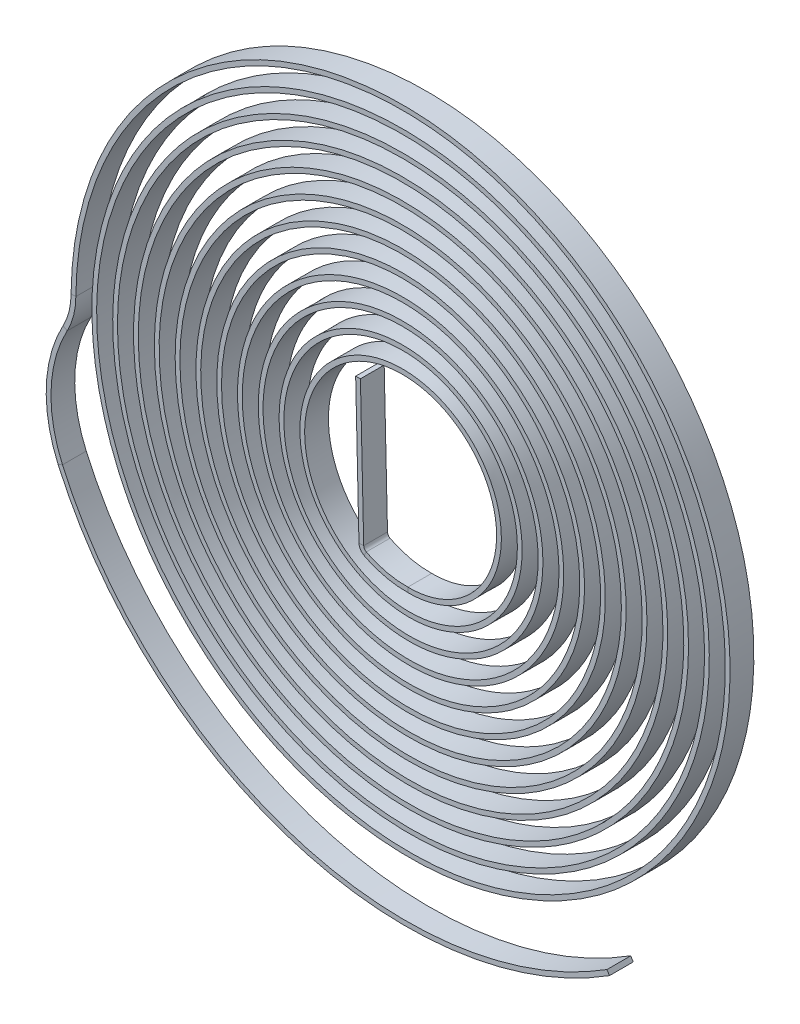
from build123d import *

# Parameters (mm, degrees)
SKETCH5_W = 0.05
SKETCH5_H = 0.25


with BuildPart() as part:
    # Sweep1: sweep along a curve in space
    with BuildLine() as sweep1_path:
        Line((-0.527391727, 0.74651346, 0), (-0.492657587, -0.75616698, 0))
        ThreePointArc((-0.492657587, -0.75616698, 0), (-0.477577264, -0.806706693, 0), (-0.438882443, -0.842545074, 0))
        ThreePointArc((-0.438882443, -0.842545074, 0), (-0.215245274, -0.925294262, 0), (0.021953184, -0.949746312, 0))
        add(Edge.make_bspline(
            [(0.021953184, -0.949746312, 0), (0.20464789, -0.952217859, 0), (0.389822394, -0.900506936, 0), (0.705202842, -0.70109414, 0), (0.834782567, -0.553674341, 0), (0.99342503, -0.207439698, 0), (1.022111196, -0.009215641, 0), (0.964949134, 0.375118929, 0), (0.879109832, 0.56051511, 0), (0.616350676, 0.85714961, 0), (0.439837367, 0.9677838, 0), (0.050338028, 1.075010841, 0), (-0.161964222, 1.07131561, 0), (-0.554221229, 0.946279934, 0), (-0.733432515, 0.825075444, 0), (-0.998794363, 0.500277335, 0), (-1.084387269, 0.297214126, 0), (-1.130364799, -0.127435335, 0), (-1.090570022, -0.348258959, 0), (-0.893905568, -0.736091011, 0), (-0.73730797, -0.902350026, 0), (-0.354208962, -1.123922593, 0), (-0.128356523, -1.17874959, 0), (0.321291507, -1.155007637, 0), (0.544263847, -1.076385751, 0), (0.91437221, -0.806619657, 0), (1.060778159, -0.615888457, 0), (1.226517515, -0.180675337, 0), (1.245459442, 0.063049115, 0), (1.145290213, 0.525749128, 0), (1.026267168, 0.743862673, 0), (0.684408327, 1.082421421, 0), (0.462126557, 1.202182446, 0), (-0.016633508, 1.300983988, 0), (-0.272260576, 1.279750531, 0), (-0.734587541, 1.098561932, 0), (-0.940411583, 0.938846633, 0), (-1.233529618, 0.528506447, 0), (-1.32021229, 0.278571719, 0), (-1.342365518, -0.232943032, 0), (-1.277699606, -0.49359721, 0), (-1.013310654, -0.941030531, 0), (-0.813985384, -1.126947258, 0), (-0.3414131, -1.361153696, 0), (-0.068982405, -1.408931383, 0), (0.462509511, -1.34654693, 0), (0.720593398, -1.236402564, 0), (1.137955304, -0.889268715, 0), (1.296413155, -0.652836161, 0), (1.459150423, -0.126864699, 0), (1.463042085, 0.161746722, 0), (1.310435649, 0.698772172, 0), (1.154122275, 0.946183908, 0), (0.727480682, 1.31812047, 0), (0.457864509, 1.441896813, 0), (-0.11023446, 1.522005159, 0), (-0.407698379, 1.478096248, 0), (-0.934538113, 1.232115061, 0), (-1.1629159, 1.030402496, 0), (-1.47440607, 0.530329578, 0), (-1.556870762, 0.232826923, 0), (-1.545047719, -0.363923108, 0), (-1.450685194, -0.662084369, 0), (-1.110964188, -1.162194846, 0), (-0.866143247, -1.363181376, 0), (-0.301519611, -1.600058144, 0), (0.017294601, -1.635429263, 0), (0.627332879, -1.524647991, 0), (0.917431554, -1.378602102, 0), (1.373944339, -0.947738853, 0), (1.5394631, -0.66363413, 0), (1.68893002, -0.046014742, 0), (1.672513095, 0.286400713, 0), (1.458384414, 0.892873398, 0), (1.260970793, 1.165797003, 0), (0.744610638, 1.562051562, 0), (0.426543335, 1.684586417, 0), (-0.230066154, 1.73571247, 0), (-0.567423277, 1.66411481, 0), (-1.15244761, 1.34517913, 0), (-1.399006244, 1.098335794, 0), (-1.71909999, 0.505161191, 0), (-1.791969046, 0.15986144, 0), (-1.736145006, -0.519595406, 0), (-1.607457315, -0.852510718, 0), (-1.185394525, -1.39769131, 0), (-0.892709725, -1.608907623, 0), (-0.234330781, -1.838246071, 0), (0.130199499, -1.855860818, 0), (0.814620467, -1.687201064, 0), (1.133245324, -1.50113932, 0), (1.620229955, -0.980886984, 0), (1.787635174, -0.647575242, 0), (1.913464562, 0.061678573, 0), (1.871565444, 0.436349665, 0), (1.587240414, 1.106580898, 0), (1.34524209, 1.400886518, 0), (0.735014906, 1.811945112, 0), (0.367840183, 1.927871894, 0), (-0.375543667, 1.939776684, 0), (-0.750404673, 1.835636793, 0), (-1.386552511, 1.436123059, 0), (-1.64663319, 1.141392992, 0), (-1.96524243, 0.452599406, 0), (-2.023105164, 0.059745944, 0), (-1.91345345, -0.699001211, 0), (-1.746042757, -1.063503681, 0), (-1.235279905, -1.645511825, 0), (-0.892782597, -1.861897412, 0), (-0.139837535, -2.073312792, 0), (0.269269401, -2.067866081, 0), (1.023065008, -1.832187044, 0), (1.366356578, -1.602290636, 0), (1.874613156, -0.987736728, 0), (2.038581338, -0.604133429, 0), (2.130378295, 0.195830656, 0), (2.057944767, 0.61075031, 0), (1.695224011, 1.338273486, 0), (1.405509004, 1.649513451, 0), (0.698089319, 2.065470106, 0), (0.281619899, 2.169348761, 0), (-0.545898457, 2.131914976, 0), (-0.955441004, 1.990574282, 0), (-1.634960832, 1.503454971, 0), (-1.903648626, 1.158482245, 0), (-2.210432883, 0.372429145, 0), (-2.247882809, -0.067259521, 0), (-2.074844745, -0.901008077, 0), (-1.864576528, -1.293535135, 0), (-1.259456848, -1.903544073, 0), (-0.865635294, -2.119850978, 0), (-0.018220337, -2.30285279, 0), (0.43385538, -2.269121425, 0), (1.251199996, -1.957689693, 0), (1.614951193, -1.680464556, 0), (2.13481775, -0.967484881, 0), (2.289911795, -0.532967582, 0), (2.337325417, 0.355869662, 0), (2.229462777, 0.808581622, 0), (1.780682971, 1.586189467, 0), (1.440496855, 1.909625987, 0), (0.633413209, 2.320247436, 0), (0.167936708, 2.406601336, 0), (-0.74018198, 2.309904486, 0), (-1.181165937, 2.126933458, 0), (-1.895662555, 1.545831576, 0), (-2.167817817, 1.148680565, 0), (-2.452253146, 0.264624304, 0), (-2.463925365, -0.220706121, 0), (-2.218279012, -1.124315577, 0), (-1.961313283, -1.540929562, 0), (-1.256927728, -2.169583324, 0), (-0.810722009, -2.380410446, 0), (0.130150908, -2.524473751, 0), (0.623125322, -2.457353314, 0), (1.497407436, -2.061907337, 0), (1.877088946, -1.734211641, 0), (2.39850323, -0.919506991, 0), (2.539208726, -0.433924495, 0), (2.532003913, 0.541038856, 0), (2.384010375, 1.028649841, 0), (1.842102764, 1.848436181, 0), (1.44909168, 2.17907087, 0), (0.540752833, 2.573863512, 0), (0.027034905, 2.637216772, 0), (-0.957270253, 2.4715956, 0), (-1.426055456, 2.242826722, 0), (-2.166540708, 1.562066803, 0), (-2.436831964, 1.111240108, 0), (-2.688281315, 0.129348925, 0), (-2.668889864, -0.399957825, 0), (-2.341817166, -1.36746196, 0), (-2.034638149, -1.803872997, 0), (-1.226867513, -2.44134477, 0), (-0.727681891, -2.641173246, 0), (0.304717952, -2.735810578, 0), (0.836067746, -2.630351818, 0), (1.759926413, -2.143164014, 0), (2.150714101, -1.762233745, 0), (2.663278046, -0.843362011, 0), (2.784040202, -0.30704083, 0), (2.712169214, 0.750399959, 0), (2.519570386, 1.269594436, 0), (1.878116182, 2.123000259, 0), (1.430347653, 2.455605353, 0), (0.420063821, 2.823884113, 0), (-0.140651458, 2.858799112, 0), (-1.195869367, 2.614924894, 0), (-1.688435796, 2.336484312, 0), (-2.445383051, 1.551139635, 0), (-2.708321195, 1.04559357, 0), (-2.916105855, -0.033042614, 0), (-2.86048082, -0.604193979, 0), (-2.443632809, -1.628831683, 0), (-2.083076909, -2.080422746, 0), (-1.168629604, -2.716476327, 0), (-0.616342264, -2.899705811, 0), (0.504736296, -2.934539306, 0), (1.07149658, -2.78598386, 0), (2.036862448, -2.199919989, 0), (2.433666644, -1.763392502, 0), (2.926713177, -0.738796005, 0), (3.021974231, -0.152544088, 0), (2.875647595, 0.982837461, 0), (2.634229856, 1.529894954, 0), (1.887512208, 2.407758562, 0), (1.383493639, 2.736909654, 0), (0.27149264, 3.067868393, 0), (-0.33449988, 3.068983313, 0), (-1.454521911, 2.737927664, 0), (-1.966492203, 2.406265332, 0), (-2.729894302, 1.512201104, 0), (-2.979867931, 0.951358651, 0), (-3.133339667, -0.222006419, 0), (-3.03646386, -0.832412862, 0), (-2.522023563, -1.906663777, 0), (-2.105305479, -2.36851781, 0), (-1.081750772, -2.992571839, 0), (-0.476720876, -3.153557491, 0), (0.729278267, -3.118390856, 0), (1.328056881, -2.922206099, 0), (2.326197589, -2.230781596, 0), (2.723694107, -1.736717, 0), (3.186355969, -0.605744879, 0), (3.250592863, 0.02914742, 0), (3.020349265, 1.237063884, 0), (2.72619185, 1.807878753, 0), (1.869244106, 2.700489729, 0), (1.307938869, 3.020599875, 0), (0.095377063, 3.303382982, 0), (-0.553701715, 3.265449165, 0), (-1.731614277, 2.83875, 0), (-2.258278462, 2.450668157, 0), (-3.017708852, 1.444580407, 0), (-3.249020548, 0.828341564, 0), (-3.33763408, -0.436810898, 0), (-3.194679095, -1.083436216, 0), (-2.575421805, -2.199061011, 0), (-2.100158642, -2.665989977, 0), (-0.965955141, -3.267184615, 0), (-0.309027159, -3.400274617, 0), (0.977237077, -3.285164566, 0), (1.604231457, -3.037077397, 0), (2.625801194, -2.234510359, 0), (3.018463931, -1.681410611, 0), (3.439744152, -0.444336136, 0), (3.467506272, 0.237425601, 0), (3.144281059, 1.51162597, 0), (2.793786699, 2.101729551, 0), (1.822436682, 2.998886303, 0), (1.203277682, 3.304241312, 0), (-0.10775437, 3.528016104, 0), (-0.797265464, 3.445935034, 0), (-2.025384826, 2.915660319, 0), (-2.561727166, 2.46834015, 0), (-3.120234721, 1.627927628, 0), (-3.265990704, 1.320388293, 0), (-3.464213001, 0.67552283, 0), (-3.516653646, 0.338269785, 0), (-3.52, 0, 0)],
            knots=[0, 0, 0, 0, 0.0078125, 0.0078125, 0.015625, 0.015625, 0.0234375, 0.0234375, 0.03125, 0.03125, 0.0390625, 0.0390625, 0.046875, 0.046875, 0.0546875, 0.0546875, 0.0625, 0.0625, 0.0703125, 0.0703125, 0.078125, 0.078125, 0.0859375, 0.0859375, 0.09375, 0.09375, 0.1015625, 0.1015625, 0.109375, 0.109375, 0.1171875, 0.1171875, 0.125, 0.125, 0.1328125, 0.1328125, 0.140625, 0.140625, 0.1484375, 0.1484375, 0.15625, 0.15625, 0.1640625, 0.1640625, 0.171875, 0.171875, 0.1796875, 0.1796875, 0.1875, 0.1875, 0.1953125, 0.1953125, 0.203125, 0.203125, 0.2109375, 0.2109375, 0.21875, 0.21875, 0.2265625, 0.2265625, 0.234375, 0.234375, 0.2421875, 0.2421875, 0.25, 0.25, 0.2578125, 0.2578125, 0.265625, 0.265625, 0.2734375, 0.2734375, 0.28125, 0.28125, 0.2890625, 0.2890625, 0.296875, 0.296875, 0.3046875, 0.3046875, 0.3125, 0.3125, 0.3203125, 0.3203125, 0.328125, 0.328125, 0.3359375, 0.3359375, 0.34375, 0.34375, 0.3515625, 0.3515625, 0.359375, 0.359375, 0.3671875, 0.3671875, 0.375, 0.375, 0.3828125, 0.3828125, 0.390625, 0.390625, 0.3984375, 0.3984375, 0.40625, 0.40625, 0.4140625, 0.4140625, 0.421875, 0.421875, 0.4296875, 0.4296875, 0.4375, 0.4375, 0.4453125, 0.4453125, 0.453125, 0.453125, 0.4609375, 0.4609375, 0.46875, 0.46875, 0.4765625, 0.4765625, 0.484375, 0.484375, 0.4921875, 0.4921875, 0.5, 0.5, 0.5078125, 0.5078125, 0.515625, 0.515625, 0.5234375, 0.5234375, 0.53125, 0.53125, 0.5390625, 0.5390625, 0.546875, 0.546875, 0.5546875, 0.5546875, 0.5625, 0.5625, 0.5703125, 0.5703125, 0.578125, 0.578125, 0.5859375, 0.5859375, 0.59375, 0.59375, 0.6015625, 0.6015625, 0.609375, 0.609375, 0.6171875, 0.6171875, 0.625, 0.625, 0.6328125, 0.6328125, 0.640625, 0.640625, 0.6484375, 0.6484375, 0.65625, 0.65625, 0.6640625, 0.6640625, 0.671875, 0.671875, 0.6796875, 0.6796875, 0.6875, 0.6875, 0.6953125, 0.6953125, 0.703125, 0.703125, 0.7109375, 0.7109375, 0.71875, 0.71875, 0.7265625, 0.7265625, 0.734375, 0.734375, 0.7421875, 0.7421875, 0.75, 0.75, 0.7578125, 0.7578125, 0.765625, 0.765625, 0.7734375, 0.7734375, 0.78125, 0.78125, 0.7890625, 0.7890625, 0.796875, 0.796875, 0.8046875, 0.8046875, 0.8125, 0.8125, 0.8203125, 0.8203125, 0.828125, 0.828125, 0.8359375, 0.8359375, 0.84375, 0.84375, 0.8515625, 0.8515625, 0.859375, 0.859375, 0.8671875, 0.8671875, 0.875, 0.875, 0.8828125, 0.8828125, 0.890625, 0.890625, 0.8984375, 0.8984375, 0.90625, 0.90625, 0.9140625, 0.9140625, 0.921875, 0.921875, 0.9296875, 0.9296875, 0.9375, 0.9375, 0.9453125, 0.9453125, 0.953125, 0.953125, 0.9609375, 0.9609375, 0.96875, 0.96875, 0.9765625, 0.9765625, 0.984375, 0.984375, 0.9921875, 0.9921875, 0.99609375, 0.99609375, 1, 1, 1, 1], degree=3))
        ThreePointArc((-3.52, 0, 0), (-3.541526355, -0.172260014, 0), (-3.604781464, -0.33392537, 0))
        ThreePointArc((-3.604781464, -0.33392537, 0), (-3.780456072, -0.972328086, 0), (-3.656080905, -1.622674465, 0))
        ThreePointArc((-3.656080905, -1.622674465, 0), (-1.159367101, -3.828298307, 0), (2.14153853, -3.378433472, 0))
    # Sketch5 → Sweep1 (sweep)
    with BuildSketch(Plane(origin=(0, 0, 0), x_dir=(0.5353846324812214, -0.8446083680043359, 0), z_dir=(-0.8446083680043358, -0.5353846324812213, 0))):
        with Locations((3.975, 0.125)):
            Rectangle(SKETCH5_W, SKETCH5_H)
    sweep(path=sweep1_path.line, transition=Transition.RIGHT)


solid = part.part
